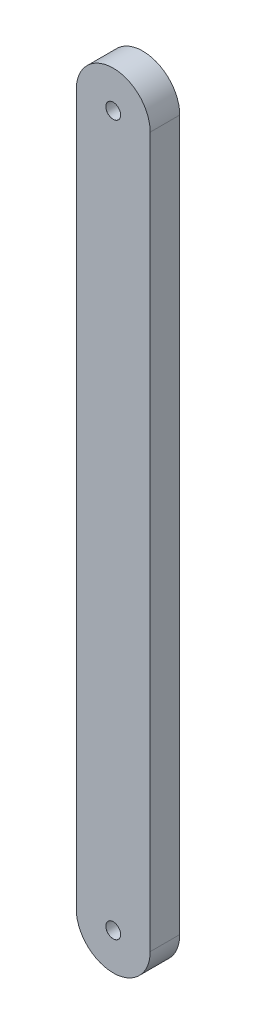
from build123d import *

# Parameters (mm, degrees)
BOSS_EXTRUDE1_DEPTH              = 20
F_10_0MM_DOWEL_HOLE1_D           = 10
F_10_0MM_DOWEL_HOLE1_DEPTH       = 20
F_10_0MM_DOWEL_HOLE1_CSINK_D     = 10.05
F_10_0MM_DOWEL_HOLE1_CSINK_ANGLE = 90


with BuildPart() as part:
    # Sketch1 → Boss-Extrude1 (new body)
    with BuildSketch(Plane.XY):
        with BuildLine():
            Line((0, 0), (0, 480))
            ThreePointArc((0, 480), (25, 505), (50, 480))
            Line((50, 480), (50, 0))
            ThreePointArc((50, 0), (25, -25), (0, 0))
        make_face()
    extrude(amount=BOSS_EXTRUDE1_DEPTH)

    # Ø10.0mm Dowel Hole1
    with Locations(Plane.XY.offset(20)):
        with Locations((25, 480), (25, 0)):
            CounterSinkHole(F_10_0MM_DOWEL_HOLE1_D / 2, F_10_0MM_DOWEL_HOLE1_CSINK_D / 2, depth=F_10_0MM_DOWEL_HOLE1_DEPTH, counter_sink_angle=F_10_0MM_DOWEL_HOLE1_CSINK_ANGLE)


solid = part.part
